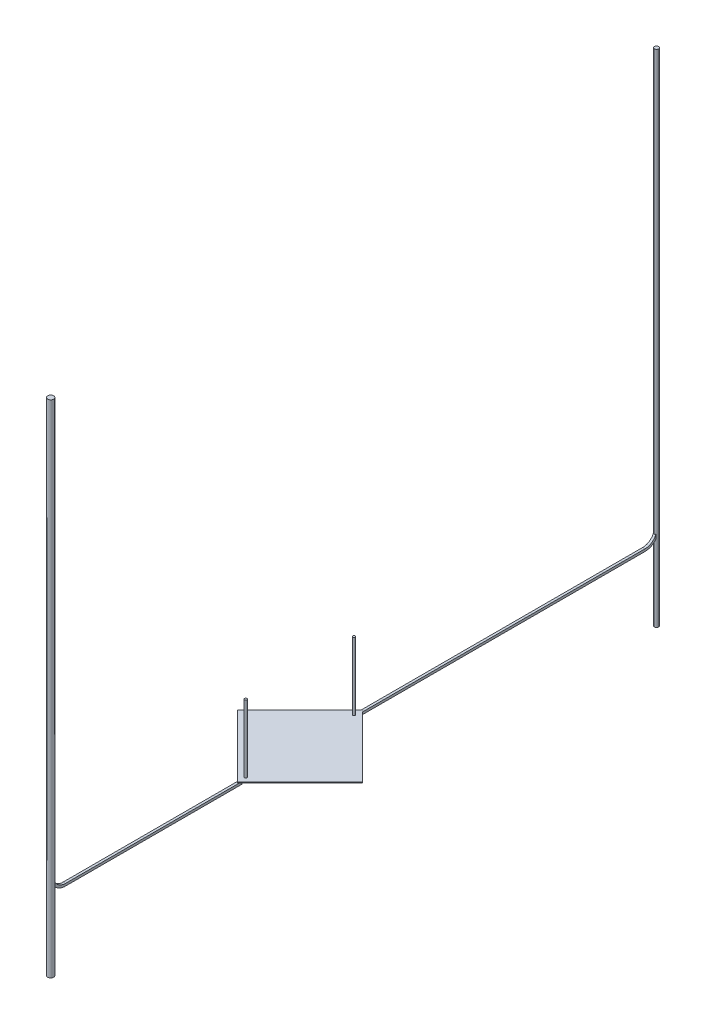
from build123d import *

# Parameters (mm, degrees)
SKETCH_1_W         = 15
SKETCH_1_H         = 15
EXTRUDE_1_DEPTH    = 0.1
SKETCH_2_R         = 0.2
EXTRUDE_2_DEPTH    = 11.5
EXTRUDE_2_2_DEPTH  = 11.5
EXTRUDE_3_DEPTH    = 0.05
SKETCH_3_W         = 0.8
SKETCH_3_H         = 2.5
EXTRUDE_3_2_DEPTH  = 0.05
EXTRUDE_3_3_DEPTH  = 0.05
SKETCH_4_W         = 4.2
SKETCH_4_H         = 2.5
EXTRUDE_4_DEPTH    = 0.05
SKETCH_5_R         = 0.1
EXTRUDE_5_DEPTH    = 0.3
EXTRUDE_6_DEPTH    = 0.05
SKETCH_7_W         = 1
SKETCH_7_H         = 1
EXTRUDE_7_DEPTH    = 0.3
MOVE_BODY_20_ANGLE = 45
SKETCH_27_R        = 0.35
EXTRUDE_30_DEPTH   = 72.5
SKETCH_28_R        = 0.5
EXTRUDE_31_DEPTH   = 72.5
SKETCH_29_W        = 49.2
SKETCH_29_H        = 0.4
EXTRUDE_32_DEPTH   = 0.2
SKETCH_33_W        = 30.004797875
SKETCH_33_H        = 0.4
EXTRUDE_34_DEPTH   = 0.2
SKETCH_40_W        = 0.4
SKETCH_40_H        = 0.4
REVOLVE_1_ANGLE    = 90
SKETCH_41_W        = 0.4
SKETCH_41_H        = 0.4
REVOLVE_2_ANGLE    = 90
SKETCH_43_R        = 0.35
EXTRUDE_35_DEPTH   = 12.5
SKETCH_44_R        = 0.5
EXTRUDE_36_DEPTH   = 12.5


with BuildPart() as part:
    # 草图1 → 凸台-拉伸1 (new body)
    with BuildSketch(Plane(origin=(0, 0, 0), x_dir=(1, 0, 0), z_dir=(0, 1, 0))):
        with Locations((7.5, 7.5)):
            Rectangle(SKETCH_1_W, SKETCH_1_H)
    extrude(amount=EXTRUDE_1_DEPTH)


with BuildPart() as body_2:
    # 草图2 → 凸台-拉伸2 (new body)
    with BuildSketch(Plane(origin=(0, 0.1, 0), x_dir=(1, 0, 0), z_dir=(0, 1, 0))):
        with Locations(Location((1, 1, 0), (0, 0, 270))):
            Circle(SKETCH_2_R)
    extrude(amount=EXTRUDE_2_DEPTH)


with BuildPart() as body_3:
    # 草图2 → Extrude 2 2 (new body)
    with BuildSketch(Plane(origin=(0, 0.1, 0), x_dir=(1, 0, 0), z_dir=(0, 1, 0))):
        with Locations(Location((14, 14, 0), (0, 0, 270))):
            Circle(SKETCH_2_R)
    extrude(amount=EXTRUDE_2_2_DEPTH)


with BuildPart() as body_4:
    # 草图3 → 凸台-拉伸3 (new body)
    with BuildSketch(Plane.XZ):
        Polygon((9.5, -14.5), (0.5, -14.5), (0.5, -0.5), (7.5, -0.5), (7.5, -9.5), (14.5, -9.5), (14.5, -14.5), align=None)
    extrude(amount=EXTRUDE_3_DEPTH)


with BuildPart() as body_5:
    # 草图3 → Extrude 3 2 (new body)
    with BuildSketch(Plane.XZ):
        with Locations((9.1, -1.75)):
            Rectangle(SKETCH_3_W, SKETCH_3_H)
    extrude(amount=EXTRUDE_3_2_DEPTH)

    # 草图5 → 凸台-拉伸5 (add)
    with BuildSketch(Plane.XZ.offset(0.05)):
        with Locations(Location((9.1, -0.9, 0), (0, 0, 270))):
            Circle(SKETCH_5_R)
    extrude(amount=EXTRUDE_5_DEPTH)


with BuildPart() as body_6:
    # 草图3 → Extrude 3 3 (new body)
    with BuildSketch(Plane.XZ):
        with Locations((14.1, -1.75)):
            Rectangle(SKETCH_3_W, SKETCH_3_H)
    extrude(amount=EXTRUDE_3_3_DEPTH)


with BuildPart() as body_7:
    # 草图4 → 凸台-拉伸4 (new body)
    with BuildSketch(Plane.XZ):
        with Locations((11.6, -1.75)):
            Rectangle(SKETCH_4_W, SKETCH_4_H)
    extrude(amount=EXTRUDE_4_DEPTH)


with BuildPart() as body_8:
    # 草图6 → 凸台-拉伸6 (new body)
    with BuildSketch(Plane.XZ.offset(0.35)):
        Polygon((9.1, -0.5), (0.5, -0.5), (0.5, -14.5), (9.5, -14.5), (9.5, -0.5), align=None)
    extrude(amount=EXTRUDE_6_DEPTH)


with BuildPart() as body_9:
    # 草图7 → 凸台-拉伸7 (new body)
    with BuildSketch(Plane.XZ.offset(0.05)):
        with Locations((13, -13)):
            Rectangle(SKETCH_7_W, SKETCH_7_H)
    extrude(amount=EXTRUDE_7_DEPTH)


with BuildPart() as body_6_1:
    # Move Body 19: moved
    add(body_6.part.moved(Location((-14, 0, 14))))


with BuildPart() as part_1:
    # Move Body 19: moved
    add(part.part.moved(Location((-14, 0, 14))))


with BuildPart() as body_9_1:
    # Move Body 19: moved
    add(body_9.part.moved(Location((-14, 0, 14))))


with BuildPart() as body_2_1:
    # Move Body 19: moved
    add(body_2.part.moved(Location((-14, 0, 14))))


with BuildPart() as body_8_1:
    # Move Body 19: moved
    add(body_8.part.moved(Location((-14, 0, 14))))


with BuildPart() as body_7_1:
    # Move Body 19: moved
    add(body_7.part.moved(Location((-14, 0, 14))))


with BuildPart() as body_5_1:
    # Move Body 19: moved
    add(body_5.part.moved(Location((-14, 0, 14))))


with BuildPart() as body_3_1:
    # Move Body 19: moved
    add(body_3.part.moved(Location((-14, 0, 14))))


with BuildPart() as body_4_1:
    # Move Body 19: moved
    add(body_4.part.moved(Location((-14, 0, 14))))


with BuildPart() as body_7_2:
    # Move Body 20: moved
    add(body_7_1.part.rotate(Axis((0, 0, 0), (0, 1, 0)), MOVE_BODY_20_ANGLE))


with BuildPart() as body_5_2:
    # Move Body 20: moved
    add(body_5_1.part.rotate(Axis((0, 0, 0), (0, 1, 0)), MOVE_BODY_20_ANGLE))


with BuildPart() as body_4_2:
    # Move Body 20: moved
    add(body_4_1.part.rotate(Axis((0, 0, 0), (0, 1, 0)), MOVE_BODY_20_ANGLE))


with BuildPart() as body_8_2:
    # Move Body 20: moved
    add(body_8_1.part.rotate(Axis((0, 0, 0), (0, 1, 0)), MOVE_BODY_20_ANGLE))


with BuildPart() as body_3_2:
    # Move Body 20: moved
    add(body_3_1.part.rotate(Axis((0, 0, 0), (0, 1, 0)), MOVE_BODY_20_ANGLE))


with BuildPart() as body_6_2:
    # Move Body 20: moved
    add(body_6_1.part.rotate(Axis((0, 0, 0), (0, 1, 0)), MOVE_BODY_20_ANGLE))


with BuildPart() as part_2:
    # Move Body 20: moved
    add(part_1.part.rotate(Axis((0, 0, 0), (0, 1, 0)), MOVE_BODY_20_ANGLE))


    add(body_4_2.part)  # 凸台-拉伸32 merges body 4
    # 草图29 → 凸台-拉伸32 (add, symmetric)
    with BuildSketch(Plane(origin=(0, 0, 0), x_dir=(0, 0, -1), z_dir=(1, 0, 0))):
        with Locations((24.6, -0.2)):
            Rectangle(SKETCH_29_W, SKETCH_29_H)
    extrude(amount=EXTRUDE_32_DEPTH, both=True)

    # 草图33 → 凸台-拉伸34 (add, symmetric)
    with BuildSketch(Plane(origin=(0, 0, 0), x_dir=(0, 0, -1), z_dir=(1, 0, 0))):
        with Locations((-34.197601062, -0.2)):
            Rectangle(SKETCH_33_W, SKETCH_33_H)
    extrude(amount=EXTRUDE_34_DEPTH, both=True)

    # 草图40 → 旋转1 (revolve)
    with BuildSketch(Plane(origin=(0, 0, -49.2), x_dir=(-1, 0, 0), z_dir=(0, 0, -1))):
        with Locations((0, -0.2)):
            Rectangle(SKETCH_40_W, SKETCH_40_H)
    revolve(axis=Axis((0.2, 2, -49.2), (1, 0, 0)), revolution_arc=REVOLVE_1_ANGLE)

    # 草图41 → 旋转2 (revolve)
    with BuildSketch(Plane.XY.offset(49.2)):
        with Locations((0, -0.2)):
            Rectangle(SKETCH_41_W, SKETCH_41_H)
    revolve(axis=Axis((-0.2, 2, 49.2), (-1, 0, 0)), revolution_arc=REVOLVE_2_ANGLE)


with BuildPart() as body_9_2:
    # Move Body 20: moved
    add(body_9_1.part.rotate(Axis((0, 0, 0), (0, 1, 0)), MOVE_BODY_20_ANGLE))


with BuildPart() as body_2_2:
    # Move Body 20: moved
    add(body_2_1.part.rotate(Axis((0, 0, 0), (0, 1, 0)), MOVE_BODY_20_ANGLE))


with BuildPart() as body_10:
    # 草图27 → 凸台-拉伸30 (new body)
    with BuildSketch(Plane(origin=(0, 0, 0), x_dir=(1, 0, 0), z_dir=(0, 1, 0))):
        with Locations(Location((0, 51.35, 0), (0, 0, 270))):
            Circle(SKETCH_27_R)
    extrude(amount=EXTRUDE_30_DEPTH)


    add(part_2.part)  # 凸台-拉伸35 merges part
    # 草图43 → 凸台-拉伸35 (add)
    with BuildSketch(Plane.XZ):
        with Locations(Location((0, -51.35, 0), (0, 0, 270))):
            Circle(SKETCH_43_R)
    extrude(amount=EXTRUDE_35_DEPTH)


with BuildPart() as body_11:
    # 草图28 → 凸台-拉伸31 (new body)
    with BuildSketch(Plane(origin=(0, 0, 0), x_dir=(1, 0, 0), z_dir=(0, 1, 0))):
        with Locations(Location((0, -51.5, 0), (0, 0, 270))):
            Circle(SKETCH_28_R)
    extrude(amount=EXTRUDE_31_DEPTH)


    add(body_10.part)  # 凸台-拉伸36 merges body 10
    # 草图44 → 凸台-拉伸36 (add)
    with BuildSketch(Plane.XZ):
        with Locations(Location((0, 51.5, 0), (0, 0, 270))):
            Circle(SKETCH_44_R)
    extrude(amount=EXTRUDE_36_DEPTH)


solid = Compound([body_7_2.part, body_5_2.part, body_8_2.part, body_3_2.part, body_6_2.part, body_9_2.part, body_2_2.part, body_11.part])
